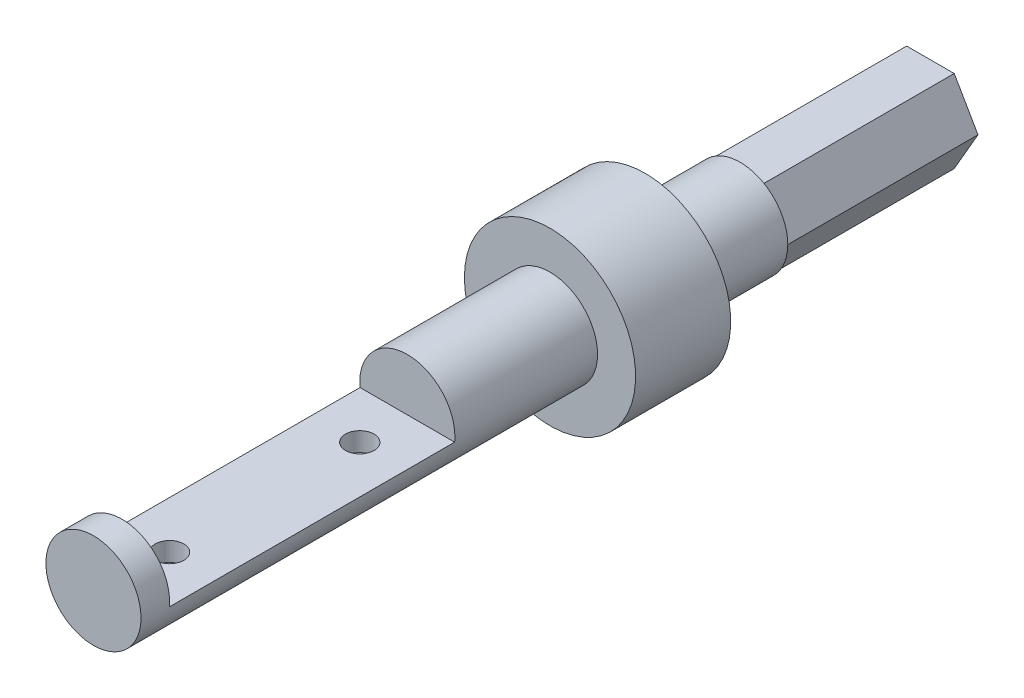
from build123d import *

# Parameters (mm, degrees)
SKETCH1_R               = 5
BOSS_EXTRUDE1_DEPTH     = 40
SKETCH2_R               = 9
BOSS_EXTRUDE2_DEPTH     = 10
SKETCH3_R               = 5
BOSS_EXTRUDE3_DEPTH     = 10
BOSS_EXTRUDE4_DEPTH     = 20
SKETCH6_R               = 5
BOSS_EXTRUDE5_DEPTH     = 8
SKETCH5_W               = 30
SKETCH5_H               = 5.5
CUT_EXTRUDE1_DEPTH      = 10
CUT_EXTRUDE1_DEPTH_BACK = 10
SKETCH8_R               = 1.5
CUT_EXTRUDE2_DEPTH      = 2


with BuildPart() as part:
    # Sketch1 → Boss-Extrude1 (new body)
    with BuildSketch(Plane.XY):
        Circle(SKETCH1_R)
    extrude(amount=BOSS_EXTRUDE1_DEPTH)

    # Sketch2 → Boss-Extrude2 (add)
    with BuildSketch(Plane(origin=(0, 0, 0), x_dir=(-1, 0, 0), z_dir=(0, 0, -1))):
        Circle(SKETCH2_R)
    extrude(amount=BOSS_EXTRUDE2_DEPTH)

    # Sketch3 → Boss-Extrude3 (add)
    with BuildSketch(Plane(origin=(0, 0, -10), x_dir=(-1, 0, 0), z_dir=(0, 0, -1))):
        Circle(SKETCH3_R)
    extrude(amount=BOSS_EXTRUDE3_DEPTH)

    # Sketch4 → Boss-Extrude4 (add)
    with BuildSketch(Plane(origin=(0, 0, -20), x_dir=(-1, 0, 0), z_dir=(0, 0, -1))):
        Polygon((-5, 0), (-2.5, -4.330127019), (2.5, -4.330127019), (5, 0), (2.5, 4.330127019), (-2.5, 4.330127019), align=None)
    extrude(amount=BOSS_EXTRUDE4_DEPTH)

    # Sketch6 → Boss-Extrude5 (add)
    with BuildSketch(Plane.XY.offset(40)):
        Circle(SKETCH6_R)
    extrude(amount=BOSS_EXTRUDE5_DEPTH)

    # Sketch5 → Cut-Extrude1 (cut, two sides)
    with BuildSketch(Plane(origin=(0, 0, 0), x_dir=(0, 0, -1), z_dir=(1, 0, 0))) as cut_extrude1_sk:
        with Locations((-30, 2.25)):
            Rectangle(SKETCH5_W, SKETCH5_H)
    extrude(amount=CUT_EXTRUDE1_DEPTH, mode=Mode.SUBTRACT)
    extrude(cut_extrude1_sk.sketch, amount=-CUT_EXTRUDE1_DEPTH_BACK, mode=Mode.SUBTRACT)

    # Sketch8 → Cut-Extrude2 (cut)
    with BuildSketch(Plane(origin=(0, -0.5, 0), x_dir=(1, 0, 0), z_dir=(0, 1, 0))):
        with Locations((0, -40)):
            Circle(SKETCH8_R)
        with Locations((0, -20)):
            Circle(SKETCH8_R)
    extrude(amount=-CUT_EXTRUDE2_DEPTH, mode=Mode.SUBTRACT)


solid = part.part
